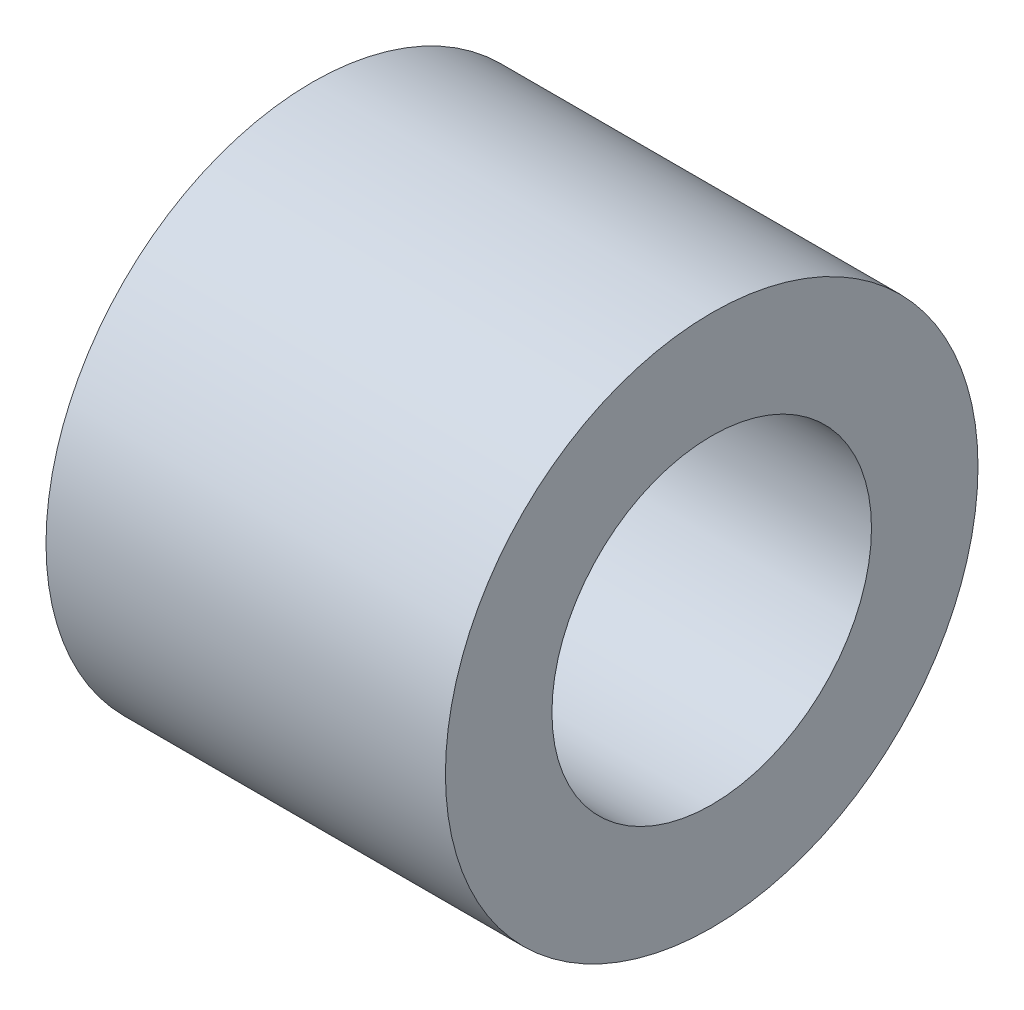
from build123d import *

# Parameters (mm, degrees)
SKETCH2_R           = 12.7
SKETCH2_R_2         = 7.62
BOSS_EXTRUDE1_DEPTH = 19.05


with BuildPart() as part:
    # Sketch2 → Boss-Extrude1 (new body)
    with BuildSketch(Plane(origin=(0, 0, 0), x_dir=(0, 0, -1), z_dir=(1, 0, 0))):
        Circle(SKETCH2_R)
        Circle(SKETCH2_R_2, mode=Mode.SUBTRACT)
    extrude(amount=BOSS_EXTRUDE1_DEPTH)


solid = part.part
